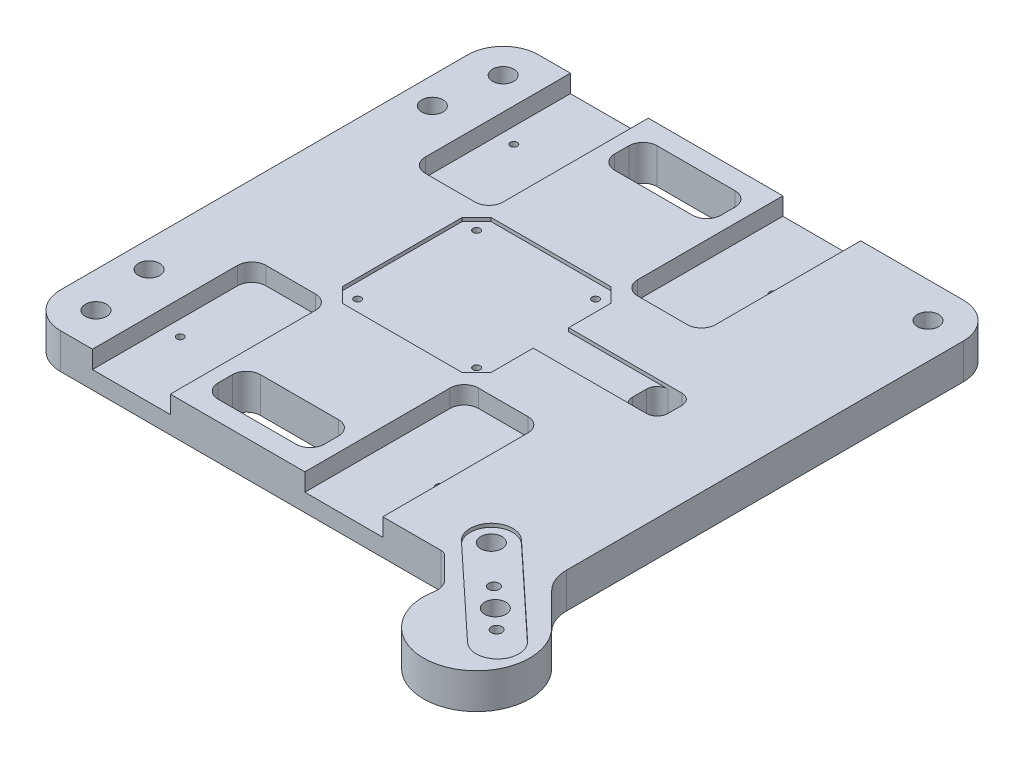
from build123d import *

# Parameters (mm, degrees)
ESQUISSE2_R         = 3
BOSS_EXTRU_1_DEPTH  = 10
BOARD_HOLES_D       = 2
BOARD_HOLES_DEPTH   = 10
STEPPER_HOLES_D     = 2
STEPPER_HOLES_DEPTH = 10
FEET_HOLES_D        = 6
FEET_HOLES_DEPTH    = 10
CHANFREIN1_SIZE     = 1
STEPPER_DEPTH       = 1
PUMPS_DEPTH         = 5
WIRES_2_DEPTH       = 11
WEIGHT_DEPTH        = 1
WEIGHT_HOLES_D      = 3
WEIGHT_HOLES_DEPTH  = 9
ESQUISSE17_W        = 10
ESQUISSE17_H        = 10
WIRES_STEPPER_DEPTH = 10
CONG_1_R            = 3


with BuildPart() as part:
    # Esquisse2 → Boss.-Extru.1 (new body)
    with BuildSketch(Plane(origin=(0, 0, 0), x_dir=(1, 0, 0), z_dir=(0, 1, 0))):
        with BuildLine():
            Line((59.233727564, -68.232233047), (65.180063204, -74.178568687))
            ThreePointArc((65.180063204, -74.178568687), (66.418060903, -76.226353952), (66.562716933, -78.614896904))
            ThreePointArc((66.562716933, -78.614896904), (85.780525757, -95.637874651), (91.923881554, -70.710678119))
            Line((91.923881554, -70.710678119), (82.928932188, -61.715728753))
            ThreePointArc((82.928932188, -61.715728753), (80.761204675, -58.471495264), (80, -54.644660941))
            Line((80, -54.644660941), (80, 57.5))
            ThreePointArc((80, 57.5), (77.071067812, 64.571067812), (70, 67.5))
            Line((70, 67.5), (-50, 67.5))
            ThreePointArc((-50, 67.5), (-57.071067812, 64.571067812), (-60, 57.5))
            Line((-60, 57.5), (-60, -57.5))
            ThreePointArc((-60, -57.5), (-57.071067812, -64.571067812), (-50, -67.5))
            Line((-50, -67.5), (57.465960611, -67.5))
            ThreePointArc((57.465960611, -67.5), (58.422669192, -67.690301169), (59.233727564, -68.232233047))
        make_face()
        with Locations((-52.5, 40)):
            Circle(ESQUISSE2_R, mode=Mode.SUBTRACT)
        with Locations((-52.5, -40)):
            Circle(ESQUISSE2_R, mode=Mode.SUBTRACT)
    extrude(amount=BOSS_EXTRU_1_DEPTH)

    # board holes
    with Locations(Plane(origin=(0, 10, 0), x_dir=(1, 0, 0), z_dir=(0, 1, 0))):
        with Locations((-36.6, 47.1), (36.6, 47.1), (36.6, -47.1), (-36.6, -47.1)):
            Hole(BOARD_HOLES_D / 2, depth=BOARD_HOLES_DEPTH)

    # stepper holes
    with Locations(Plane(origin=(0, 10, 0), x_dir=(1, 0, 0), z_dir=(0, 1, 0))):
        with Locations((-16.8, 16.8), (16.8, 16.8), (16.8, -16.8), (-16.8, -16.8)):
            Hole(STEPPER_HOLES_D / 2, depth=STEPPER_HOLES_DEPTH)

    # feet holes
    with Locations(Plane(origin=(0, 10, 0), x_dir=(1, 0, 0), z_dir=(0, 1, 0))):
        with Locations((70, 57.5), (-50, 57.5), (-50, -57.5), (78.254846073, -72.973824527), (61.661200826, -57.5)):
            Hole(FEET_HOLES_D / 2, depth=FEET_HOLES_DEPTH)

    # Chanfrein1
    chanfrein1_edges = [part.edges().sort_by_distance(p)[0] for p in [
        (-35.6, 10, 47.1),
        (37.6, 10, 47.1),
        (37.6, 10, -47.1),
        (-35.6, 10, -47.1),
    ]]
    chamfer(chanfrein1_edges, length=CHANFREIN1_SIZE)

    # Esquisse10 → stepper (cut)
    with BuildSketch(Plane(origin=(0, 10, -10), x_dir=(1, 0, 0), z_dir=(0, -1, 0))):
        Polygon((-16.9, 31), (16.9, 31), (21, 26.9), (21, 15), (56, 15), (56, 5), (21, 5), (21, -6.9), (16.9, -11), (-16.9, -11), (-21, -6.9), (-21, 26.9), align=None)
    extrude(amount=STEPPER_DEPTH, mode=Mode.SUBTRACT)

    # Esquisse11 → pumps (cut)
    with BuildSketch(Plane(origin=(0, 10, 0), x_dir=(1, 0, 0), z_dir=(0, 1, 0))):
        with BuildLine():
            Line((-41, -67.5), (-19, -67.5))
            Line((-19, -67.5), (-19, -26.5))
            ThreePointArc((-19, -26.5), (-20.171572875, -23.671572875), (-23, -22.5))
            Line((-23, -22.5), (-37, -22.5))
            ThreePointArc((-37, -22.5), (-39.828427125, -23.671572875), (-41, -26.5))
            Line((-41, -26.5), (-41, -67.5))
        make_face()
        with BuildLine():
            Line((19, -67.5), (19, -26.5))
            ThreePointArc((19, -26.5), (20.171572875, -23.671572875), (23, -22.5))
            Line((23, -22.5), (37, -22.5))
            ThreePointArc((37, -22.5), (39.828427125, -23.671572875), (41, -26.5))
            Line((41, -26.5), (41, -67.5))
            Line((41, -67.5), (19, -67.5))
        make_face()
        with BuildLine():
            Line((41, 67.5), (19, 67.5))
            Line((19, 67.5), (19, 26.5))
            ThreePointArc((19, 26.5), (20.171572875, 23.671572875), (23, 22.5))
            Line((23, 22.5), (37, 22.5))
            ThreePointArc((37, 22.5), (39.828427125, 23.671572875), (41, 26.5))
            Line((41, 26.5), (41, 67.5))
        make_face()
        with BuildLine():
            Line((-19, 67.5), (-19, 26.5))
            ThreePointArc((-19, 26.5), (-20.171572875, 23.671572875), (-23, 22.5))
            Line((-23, 22.5), (-37, 22.5))
            ThreePointArc((-37, 22.5), (-39.828427125, 23.671572875), (-41, 26.5))
            Line((-41, 26.5), (-41, 67.5))
            Line((-41, 67.5), (-19, 67.5))
        make_face()
    extrude(amount=-PUMPS_DEPTH, mode=Mode.SUBTRACT)

    # Esquisse13 → wires 2 (cut, through all)
    with BuildSketch(Plane(origin=(0, 10, 0), x_dir=(1, 0, 0), z_dir=(0, 1, 0))):
        with BuildLine():
            Line((11, 62), (-11, 62))
            ThreePointArc((-11, 62), (-13.828427125, 60.828427125), (-15, 58))
            Line((-15, 58), (-15, 54))
            ThreePointArc((-15, 54), (-13.828427125, 51.171572875), (-11, 50))
            Line((-11, 50), (11, 50))
            ThreePointArc((11, 50), (13.828427125, 51.171572875), (15, 54))
            Line((15, 54), (15, 58))
            ThreePointArc((15, 58), (13.828427125, 60.828427125), (11, 62))
        make_face()
        with BuildLine():
            Line((-15, -58), (-15, -54))
            ThreePointArc((-15, -54), (-13.828427125, -51.171572875), (-11, -50))
            Line((-11, -50), (11, -50))
            ThreePointArc((11, -50), (13.828427125, -51.171572875), (15, -54))
            Line((15, -54), (15, -58))
            ThreePointArc((15, -58), (13.828427125, -60.828427125), (11, -62))
            Line((11, -62), (-11, -62))
            ThreePointArc((-11, -62), (-13.828427125, -60.828427125), (-15, -58))
        make_face()
    extrude(amount=-WIRES_2_DEPTH, mode=Mode.SUBTRACT)

    # Esquisse14 → weight (cut)
    with BuildSketch(Plane(origin=(0, 10, 0), x_dir=(1, 0, 0), z_dir=(0, 1, 0))):
        with BuildLine():
            Line((66.257054798, -53.581738396), (91.854434355, -77.451680998))
            ThreePointArc((91.854434355, -77.451680998), (92.150566404, -85.931793368), (83.670454034, -86.227925417))
            Line((83.670454034, -86.227925417), (58.073074477, -62.357982815))
            ThreePointArc((58.073074477, -62.357982815), (57.776942428, -53.877870445), (66.257054798, -53.581738396))
        make_face()
    extrude(amount=-WEIGHT_DEPTH, mode=Mode.SUBTRACT)

    # Weight holes
    with Locations(Plane(origin=(0, 9, 0), x_dir=(1, 0, 0), z_dir=(0, 1, 0))):
        with Locations((83.691023277, -78.04314178), (72.720717752, -67.813166379), (77.572847713, -73.705178228)):
            Hole(WEIGHT_HOLES_D / 2, depth=WEIGHT_HOLES_DEPTH)

    # Esquisse17 → wires stepper (cut, through all)
    with BuildSketch(Plane(origin=(0, 9, 0), x_dir=(1, 0, 0), z_dir=(0, 1, 0))):
        with Locations((51, 0)):
            Rectangle(ESQUISSE17_W, ESQUISSE17_H)
    extrude(amount=-WIRES_STEPPER_DEPTH, mode=Mode.SUBTRACT)

    # Congé1
    cong_1_edges = [part.edges().sort_by_distance(p)[0] for p in [
        (56, 5, -5),
        (56, 5, 5),
        (46, 4.5, 5),
        (46, 4.5, -5),
    ]]
    fillet(cong_1_edges, radius=CONG_1_R)


solid = part.part
